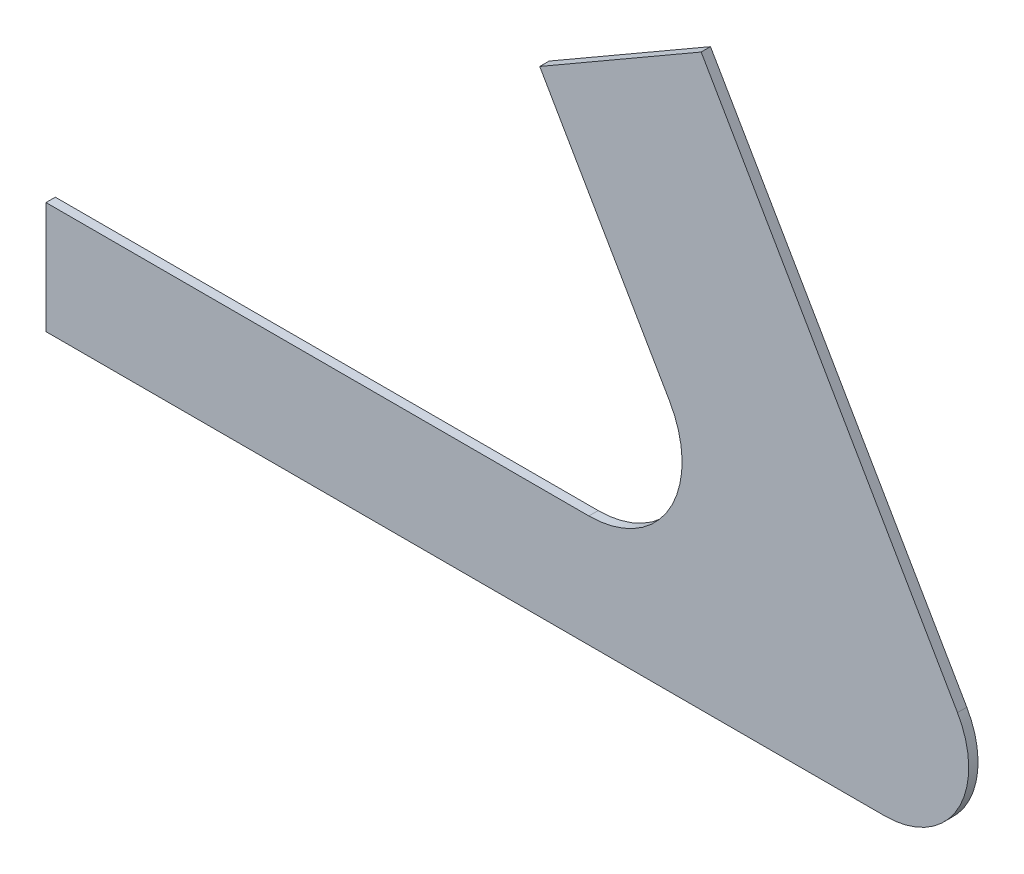
from build123d import *

# Parameters (mm, degrees)
DODANIE_WYCI_GNI_CIE1_DEPTH = 1


with BuildPart() as part:
    # Szkic1 → Dodanie-wyciągnięcie1 (new body)
    with BuildSketch(Plane.XY):
        with BuildLine():
            Line((0, 0), (0, 12))
            Line((0, 12), (58.245735195, 12))
            ThreePointArc((58.245735195, 12), (66.905989232, 17), (66.905989232, 27))
            Line((66.905989232, 27), (52.973720558, 51.131397208))
            Line((52.973720558, 51.131397208), (70.294228634, 61.131397208))
            Line((70.294228634, 61.131397208), (97.794228634, 13.5))
            ThreePointArc((97.794228634, 13.5), (97.794228634, 4.5), (90, 0))
            Line((90, 0), (0, 0))
        make_face()
    extrude(amount=DODANIE_WYCI_GNI_CIE1_DEPTH)


solid = part.part
